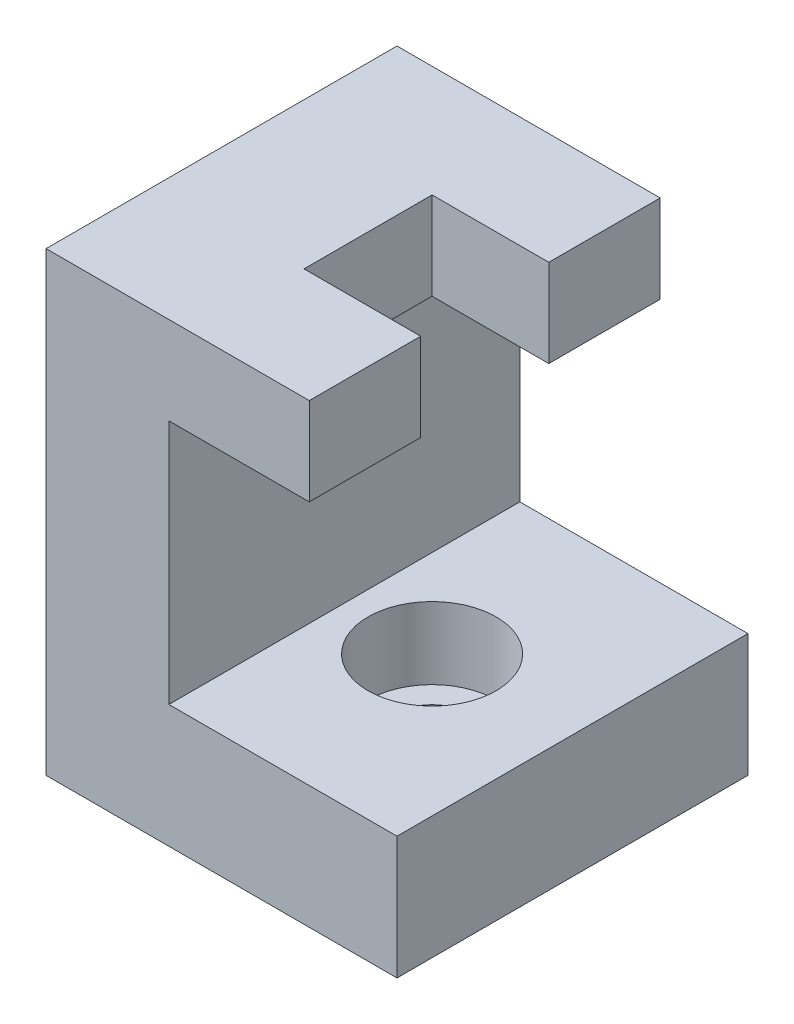
from build123d import *

# Parameters (mm, degrees)
SKETCH_1_W          = 7
SKETCH_1_H          = 14
SKETCH_1_W_2        = 20
SKETCH_1_H_2        = 7
EXTRUDE_1_DEPTH     = 10
SKETCH_2_R          = 3.65
CUT_EXTRUDE_1_DEPTH = 4.1
CUT_EXTRUDE_3_REACH = 28
SKETCH_4_W          = 7.3
SKETCH_4_H          = 7.3
CUT_EXTRUDE_2_REACH = 4.9
SKETCH_3_R          = 2.25


with BuildPart() as part:
    # 草圖1 → 填料-伸長1 (new body, symmetric)
    with BuildSketch(Plane.XY):
        with Locations((3.5, 14)):
            Rectangle(SKETCH_1_W, SKETCH_1_H)
        with Locations((10, 3.5)):
            Rectangle(SKETCH_1_W_2, SKETCH_1_H_2)
        Polygon((0, 26), (0, 21), (7, 21), (15, 21), (15, 26), align=None)
    extrude(amount=EXTRUDE_1_DEPTH, both=True)

    # 草圖2 → 除料-伸長1 (cut)
    with BuildSketch(Plane(origin=(0, 7, 0), x_dir=(1, 0, 0), z_dir=(0, 1, 0))):
        with Locations((12, 0)):
            Circle(SKETCH_2_R)
    extrude(amount=-CUT_EXTRUDE_1_DEPTH, mode=Mode.SUBTRACT)

    # 草圖4 → 除料-伸長3 (cut, up to next)
    with BuildSketch(Plane(origin=(0, 26, 0), x_dir=(1, 0, 0), z_dir=(0, 1, 0)), mode=Mode.PRIVATE) as cut_extrude_3_sk1:
        with Locations((12, 0)):
            Rectangle(SKETCH_4_W, SKETCH_4_H)
    cut_extrude_3_tool1 = extrude(cut_extrude_3_sk1.sketch, amount=-CUT_EXTRUDE_3_REACH, mode=Mode.PRIVATE) & part.part
    add(cut_extrude_3_tool1.solids().sort_by_distance((12, 26, 0))[0], mode=Mode.SUBTRACT)

    # 草圖3 → 除料-伸長2 (cut, up to next)
    with BuildSketch(Plane(origin=(0, 2.9, 0), x_dir=(1, 0, 0), z_dir=(0, 1, 0)), mode=Mode.PRIVATE) as cut_extrude_2_sk1:
        with Locations((12, 0)):
            Circle(SKETCH_3_R)
    cut_extrude_2_tool1 = extrude(cut_extrude_2_sk1.sketch, amount=-CUT_EXTRUDE_2_REACH, mode=Mode.PRIVATE) & part.part
    add(cut_extrude_2_tool1.solids().sort_by_distance((12, 2.9, 0))[0], mode=Mode.SUBTRACT)


solid = part.part
